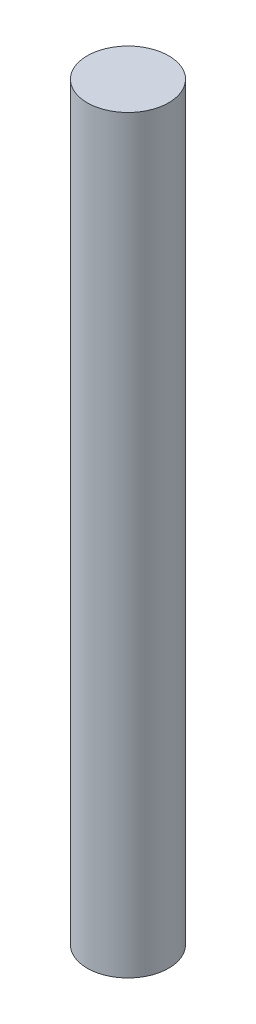
from build123d import *

# Parameters (mm, degrees)
CROQUIS1_R              = 2.5
SALIENTE_EXTRUIR1_DEPTH = 46


with BuildPart() as part:
    # Croquis1 → Saliente-Extruir1 (new body)
    with BuildSketch(Plane(origin=(0, 0, 0), x_dir=(1, 0, 0), z_dir=(0, 1, 0))):
        Circle(CROQUIS1_R)
    extrude(amount=SALIENTE_EXTRUIR1_DEPTH)


solid = part.part
